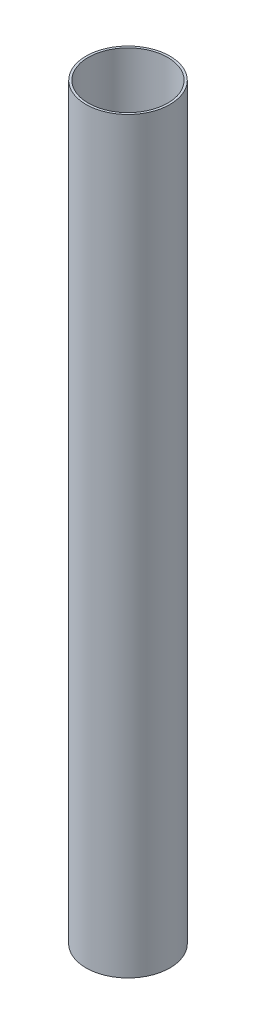
from build123d import *

# Parameters (mm, degrees)
SKETCH1_W = 1.524
SKETCH1_H = 508


with BuildPart() as part:
    # Sketch1 → Revolve1 (revolve)
    with BuildSketch(Plane.XY):
        with Locations((27.7368, 254)):
            Rectangle(SKETCH1_W, SKETCH1_H)
    revolve(axis=Axis((0, 123.620053705, 0), (0, -1, 0)))


solid = part.part
